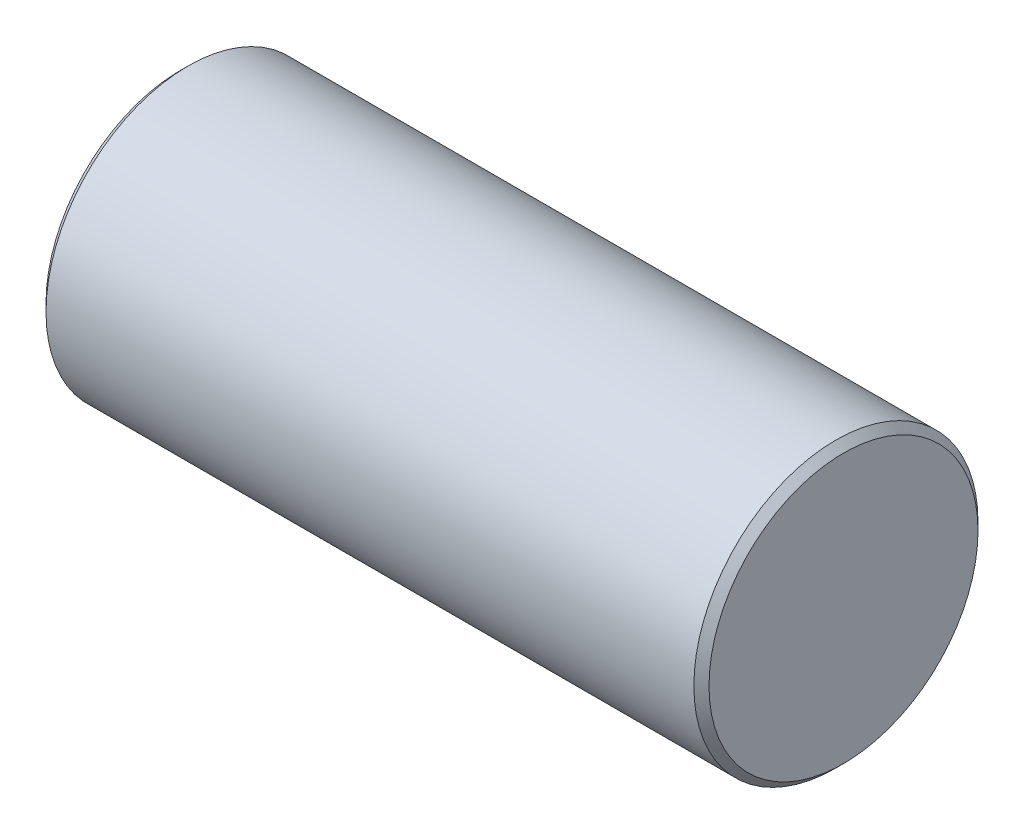
from build123d import *

# Parameters (mm, degrees)
SKETCH1_R                 = 4.7625
BOSS_EXTRUDE1_DEPTH       = 11.1125
SKETCH2_W                 = 8.255
SKETCH2_H                 = 9.525
CUT_EXTRUDE1_DEPTH        = 0.508
F_4_40_TAPPED_HOLE1_D     = 2.2606
F_4_40_TAPPED_HOLE1_DEPTH = 3.81
F_4_40_TAPPED_HOLE1_TIP   = 0.679152758
CHAMFER1_SIZE             = 0.254


with BuildPart() as part:
    # Sketch1 → Boss-Extrude1 (new body, symmetric)
    with BuildSketch(Plane(origin=(0, 0, 0), x_dir=(0, 0, -1), z_dir=(1, 0, 0))):
        Circle(SKETCH1_R)
    extrude(amount=BOSS_EXTRUDE1_DEPTH, both=True)

    # Sketch2 → Cut-Extrude1 (cut)
    with BuildSketch(Plane(origin=(0, 0, -4.7625), x_dir=(-1, 0, 0), z_dir=(0, 0, -1))):
        Rectangle(SKETCH2_W, SKETCH2_H)
    extrude(amount=-CUT_EXTRUDE1_DEPTH, mode=Mode.SUBTRACT)

    # #4-40 Tapped Hole1
    with Locations(Plane(origin=(0, 0, -4.2545), x_dir=(-1, 0, 0), z_dir=(0, 0, -1))):
        with Locations((0, 0)):
            Hole(F_4_40_TAPPED_HOLE1_D / 2, depth=F_4_40_TAPPED_HOLE1_DEPTH)
            with Locations((0, 0, -(F_4_40_TAPPED_HOLE1_DEPTH + F_4_40_TAPPED_HOLE1_TIP / 2))):  # 118° drill point
                Cone(0, F_4_40_TAPPED_HOLE1_D / 2, F_4_40_TAPPED_HOLE1_TIP, mode=Mode.SUBTRACT)

    # Chamfer1
    chamfer1_edges = [part.edges().sort_by_distance(p)[0] for p in [
        (-11.1125, 0, 4.7625),
        (11.1125, 0, 4.7625),
    ]]
    chamfer(chamfer1_edges, length=CHAMFER1_SIZE)


solid = part.part
